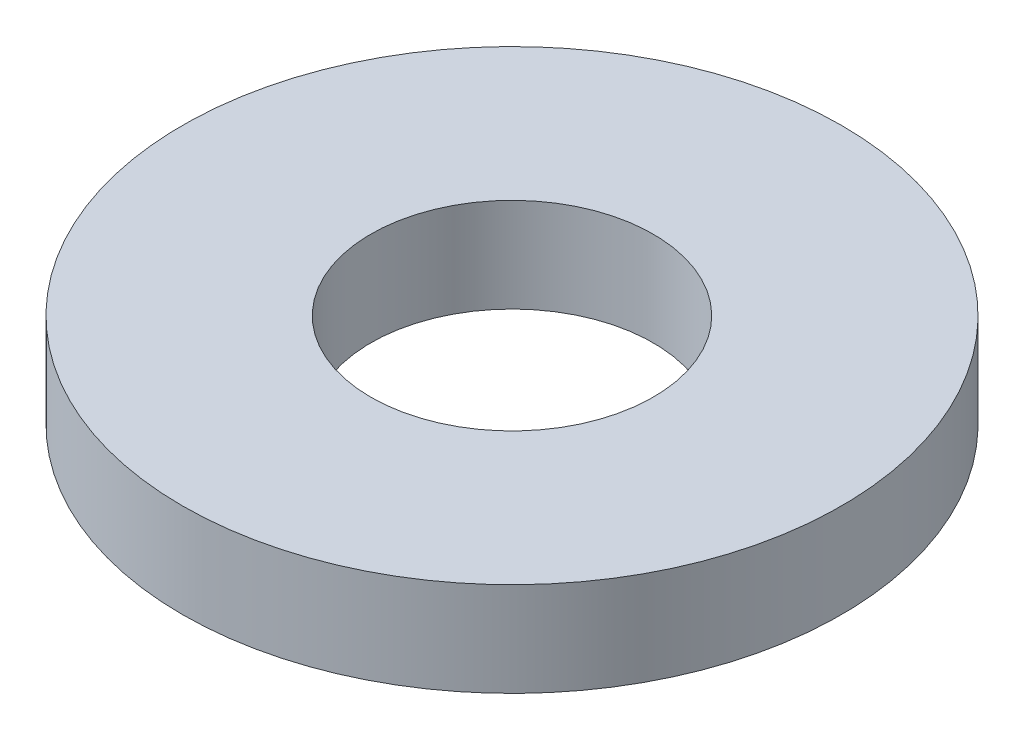
from build123d import *

# Parameters (mm, degrees)
SKETCH1_R           = 35
SKETCH1_R_2         = 15
BOSS_EXTRUDE1_DEPTH = 10


with BuildPart() as part:
    # Sketch1 → Boss-Extrude1 (new body)
    with BuildSketch(Plane(origin=(0, 0, 0), x_dir=(1, 0, 0), z_dir=(0, 1, 0))):
        Circle(SKETCH1_R)
        Circle(SKETCH1_R_2, mode=Mode.SUBTRACT)
    extrude(amount=BOSS_EXTRUDE1_DEPTH)


solid = part.part
